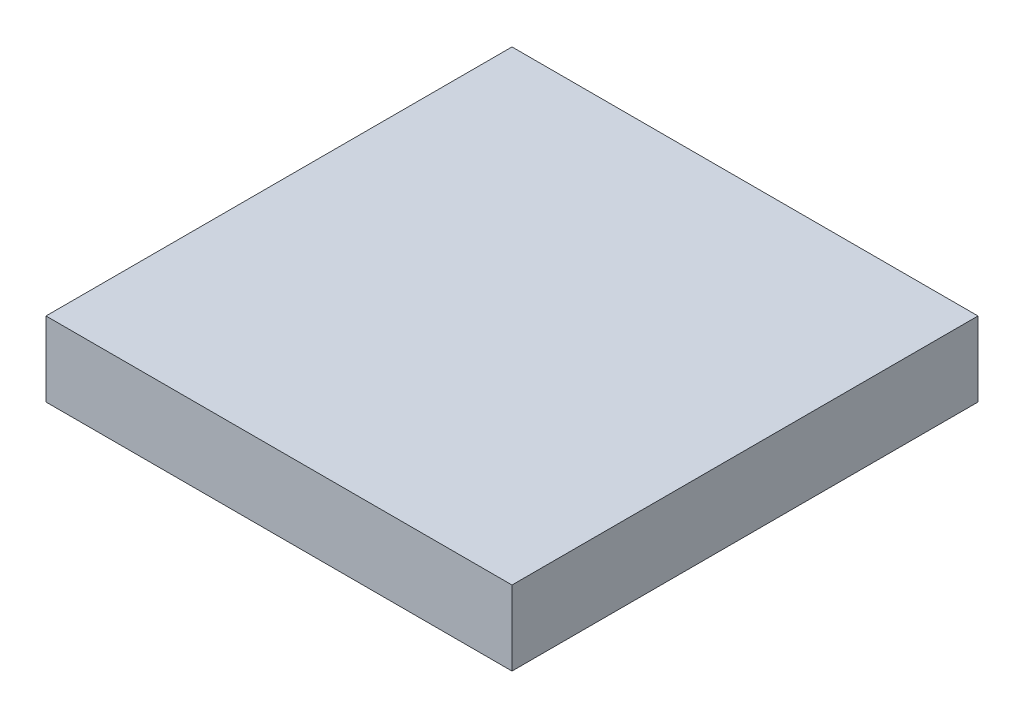
from build123d import *

# Parameters (mm, degrees)
SKETCH1_W           = 2.5
SKETCH1_H           = 2.5
BOSS_EXTRUDE1_DEPTH = 0.4


with BuildPart() as part:
    # Sketch1 → Boss-Extrude1 (new body)
    with BuildSketch(Plane(origin=(0, 0, 0), x_dir=(1, 0, 0), z_dir=(0, 1, 0))):
        Rectangle(SKETCH1_W, SKETCH1_H)
    extrude(amount=BOSS_EXTRUDE1_DEPTH)


solid = part.part
